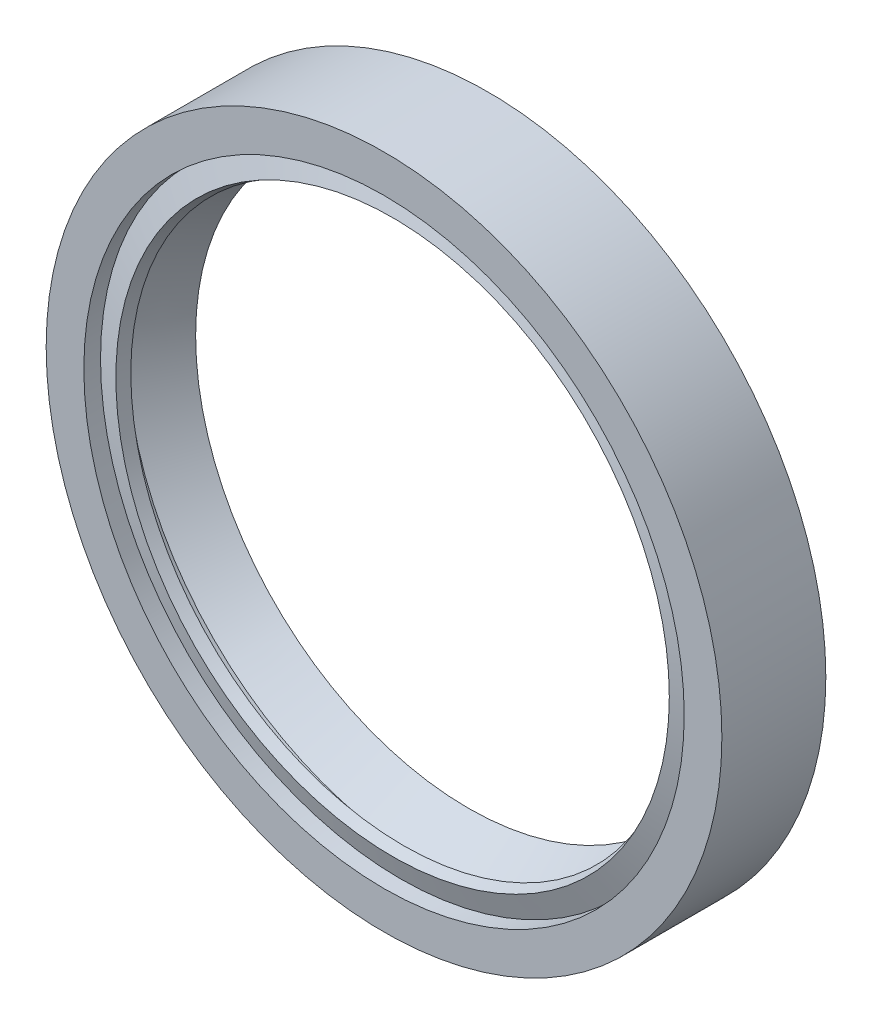
from build123d import *


with BuildPart() as part:
    # Sketch1 → Revolve1 (revolve)
    with BuildSketch(Plane(origin=(0, 0, 0), x_dir=(0, 0, -1), z_dir=(1, 0, 0))):
        Polygon((8, 26), (0, 26), (0, 23.101229145), (1.283914467, 23.101229145), (0.658486684, 21.295935435), (1.512702621, 21), (2.240654576, 23.101229145), (3.267168994, 23.101229145), (6.501757282, 21), (8, 23.162900408), (8, 24.256131168), (1.751055508, 24.256131168), (1.751055508, 25.187695876), (8, 25.187695876), align=None)
    revolve(axis=Axis((0, 0, 0), (0, 0, -1)))


solid = part.part
